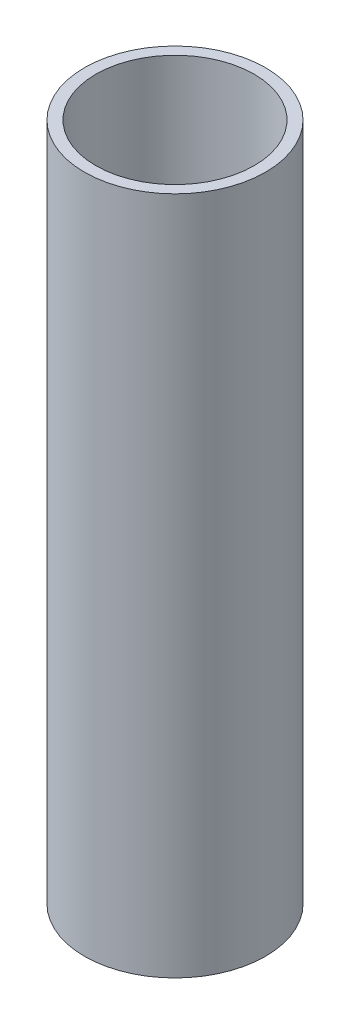
from build123d import *

# Parameters (mm, degrees)
SKETCH_1_R      = 8
SKETCH_1_R_2    = 7
EXTRUDE_1_DEPTH = 60


with BuildPart() as part:
    # 草图1 → 凸台-拉伸1 (new body)
    with BuildSketch(Plane(origin=(0, 0, 0), x_dir=(1, 0, 0), z_dir=(0, 1, 0))):
        Circle(SKETCH_1_R)
        Circle(SKETCH_1_R_2, mode=Mode.SUBTRACT)
    extrude(amount=EXTRUDE_1_DEPTH)


solid = part.part
